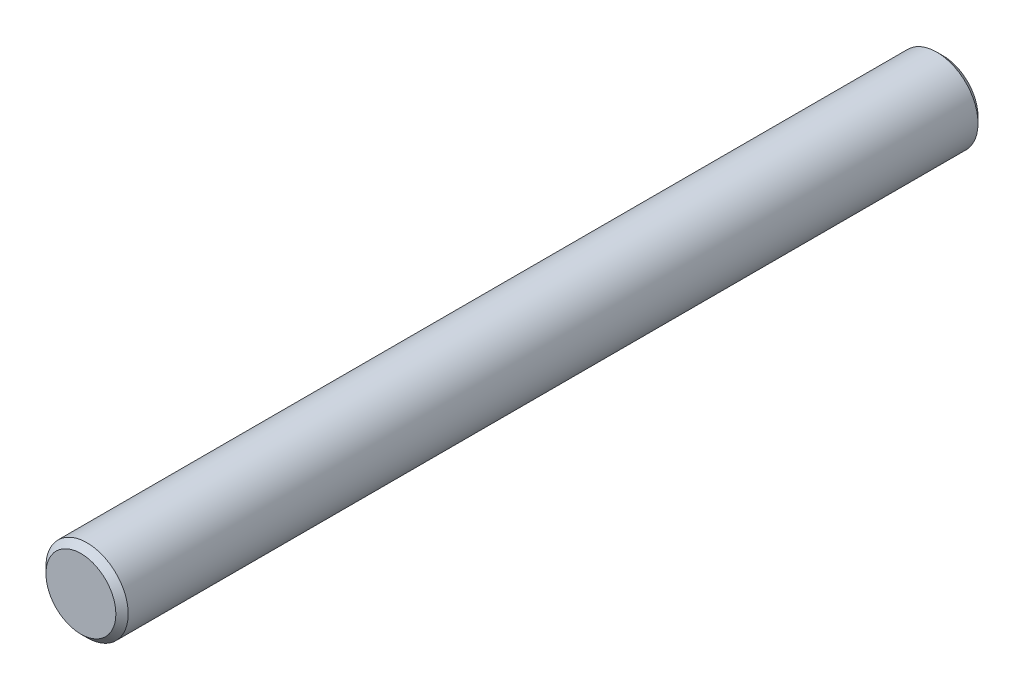
from build123d import *

# Parameters (mm, degrees)
SKETCH2_R                = 3.96875
BOSS_EXTRUDE1_DEPTH      = 41.5925
BOSS_EXTRUDE1_DEPTH_BACK = 41.5925
CHAMFER1_SIZE            = 0.5953125


with BuildPart() as part:
    # Sketch2 → Boss-Extrude1 (new body, two sides)
    with BuildSketch(Plane.XY) as boss_extrude1_sk:
        Circle(SKETCH2_R)
    extrude(amount=BOSS_EXTRUDE1_DEPTH)
    extrude(boss_extrude1_sk.sketch, amount=-BOSS_EXTRUDE1_DEPTH_BACK)

    # Chamfer1
    chamfer1_edges = [part.edges().sort_by_distance(p)[0] for p in [
        (-3.96875, 0, -41.5925),
        (-3.96875, 0, 41.5925),
    ]]
    chamfer(chamfer1_edges, length=CHAMFER1_SIZE)


solid = part.part
